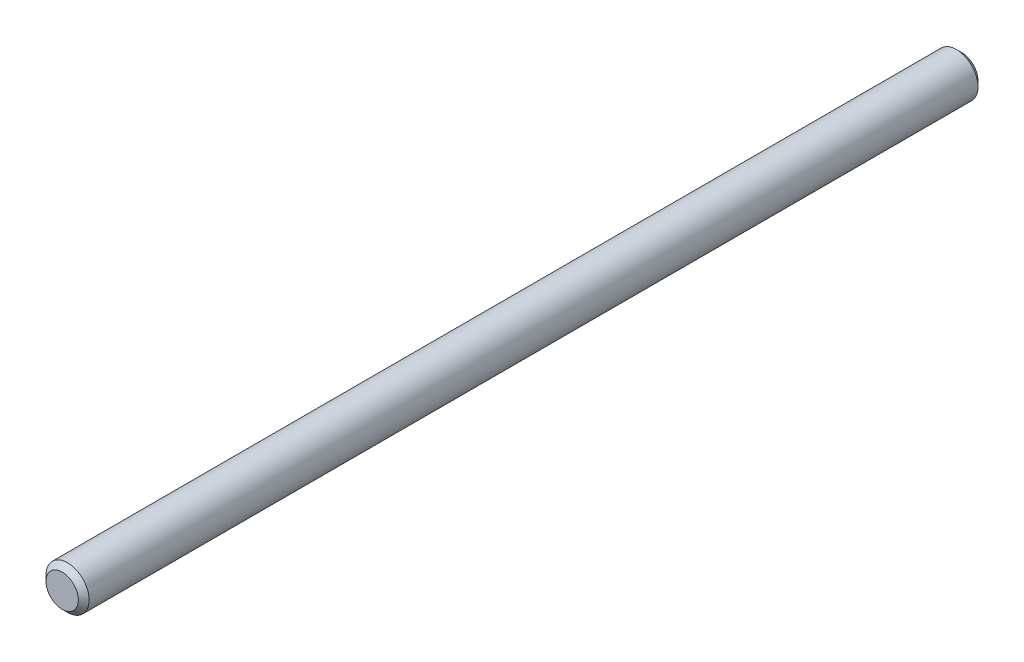
from build123d import *

# Parameters (mm, degrees)
SCHIZZO1_R                   = 4
ESTRUSIONE_ESTRUSIONE1_DEPTH = 167
SMUSSO1_SIZE                 = 1


with BuildPart() as part:
    # Schizzo1 → Estrusione-Estrusione1 (new body)
    with BuildSketch(Plane.XY.offset(99)):
        Circle(SCHIZZO1_R)
    extrude(amount=ESTRUSIONE_ESTRUSIONE1_DEPTH)

    # Smusso1
    smusso1_edges = [part.edges().sort_by_distance(p)[0] for p in [
        (-4, 0, 99),
        (-4, 0, 266),
    ]]
    chamfer(smusso1_edges, length=SMUSSO1_SIZE)


solid = part.part
